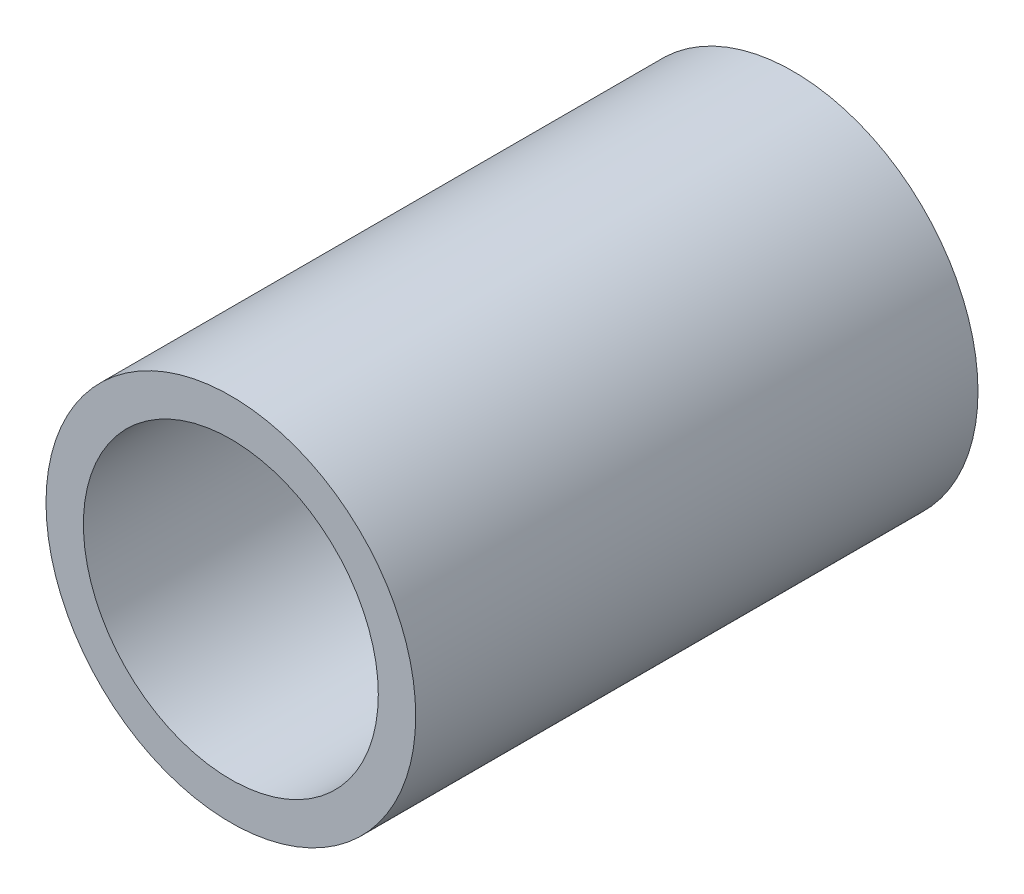
from build123d import *

# Parameters (mm, degrees)
SKETCH1_R           = 16.7005
SKETCH1_R_2         = 13.3223
EXTRUDE_THIN1_DEPTH = 25.4


with BuildPart() as part:
    # Sketch1 → Extrude-Thin1 (new body, symmetric)
    with BuildSketch(Plane.XY):
        Circle(SKETCH1_R)
        Circle(SKETCH1_R_2, mode=Mode.SUBTRACT)
    extrude(amount=EXTRUDE_THIN1_DEPTH, both=True)


solid = part.part
